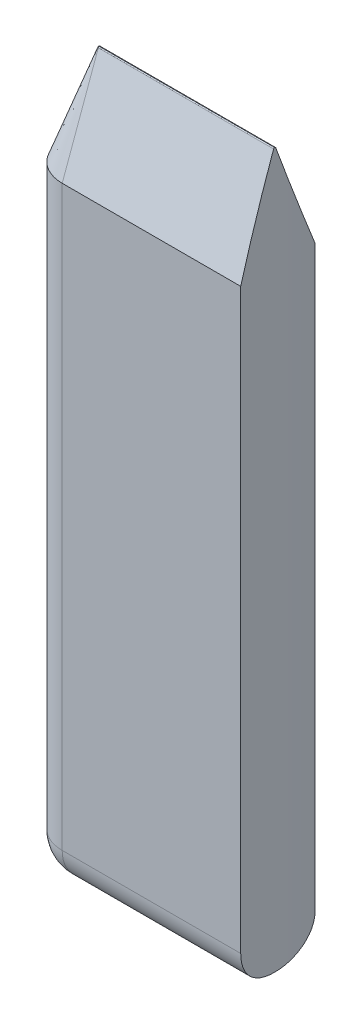
from build123d import *
from OCP.BRepFilletAPI import BRepFilletAPI_MakeChamfer

# Parameters (mm, degrees)
BOSS_EXTRUDE1_DEPTH = 100
CHAMFER1_SIZE       = 14
CHAMFER1_SIZE2      = 5.09558328
FILLET1_R           = 0.15
FILLET2_R           = 5.1


with BuildPart() as part:
    # Sketch1 → Boss-Extrude1 (new body)
    with BuildSketch(Plane(origin=(0, 0, 0), x_dir=(1, 0, 0), z_dir=(0, 1, 0))):
        with BuildLine():
            ThreePointArc((-29.54423259, -5.20944533), (-30, 0), (-29.54423259, 5.20944533))
            Line((-29.54423259, 5.20944533), (-54.54423259, 5.20944533))
            ThreePointArc((-54.54423259, 5.20944533), (-59.75367792, 0), (-54.54423259, -5.20944533))
            Line((-54.54423259, -5.20944533), (-29.54423259, -5.20944533))
        make_face()
    extrude(amount=BOSS_EXTRUDE1_DEPTH)

    # Chamfer1: one chamfer whose edges measure the first distance from different faces: ONE call of the kernel's chamfer builder (chamfer() names one face for all edges)
    chamfer1_edges_1 = [part.edges().sort_by_distance(p)[0] for p in [
        (-59.75367792, 100, 0),
    ]]
    chamfer1_side_1 = [part.faces().sort_by_distance(p)[0] for p in [
        (-59.75367792, 50, 0),
    ]]
    chamfer1_edges_2 = [part.edges().sort_by_distance(p)[0] for p in [
        (-42.04423259, 100, 5.20944533),
    ]]
    chamfer1_side_2 = [part.faces().sort_by_distance(p)[0] for p in [
        (-42.04423259, 50, 5.20944533),
    ]]
    chamfer1_edges_3 = [part.edges().sort_by_distance(p)[0] for p in [
        (-42.04423259, 100, -5.20944533),
    ]]
    chamfer1_side_3 = [part.faces().sort_by_distance(p)[0] for p in [
        (-42.04423259, 50, -5.20944533),
    ]]
    chamfer1 = BRepFilletAPI_MakeChamfer(part.part.solid().wrapped)
    for e in chamfer1_edges_1:
        chamfer1.Add(CHAMFER1_SIZE, CHAMFER1_SIZE2, e.wrapped, chamfer1_side_1[0].wrapped)  # the first distance lies on this face
    for e in chamfer1_edges_2:
        chamfer1.Add(CHAMFER1_SIZE, CHAMFER1_SIZE2, e.wrapped, chamfer1_side_2[0].wrapped)  # the first distance lies on this face
    for e in chamfer1_edges_3:
        chamfer1.Add(CHAMFER1_SIZE, CHAMFER1_SIZE2, e.wrapped, chamfer1_side_3[0].wrapped)  # the first distance lies on this face
    add(Compound.cast(chamfer1.Shape()), mode=Mode.REPLACE)

    # Fillet1
    fillet1_edges = [part.edges().sort_by_distance(p)[0] for p in [
        (-42.272008257, 100, -0.11386205),
        (-54.658094641, 100, 0),
        (-42.272008257, 100, 0.11386205),
    ]]
    fillet(fillet1_edges, radius=FILLET1_R)

    # Fillet2
    fillet2_edges = [part.edges().sort_by_distance(p)[0] for p in [
        (-42.04423259, 0, 5.20944533),
        (-59.75367792, 0, 0),
        (-42.04423259, 0, -5.20944533),
    ]]
    fillet(fillet2_edges, radius=FILLET2_R)


solid = part.part
